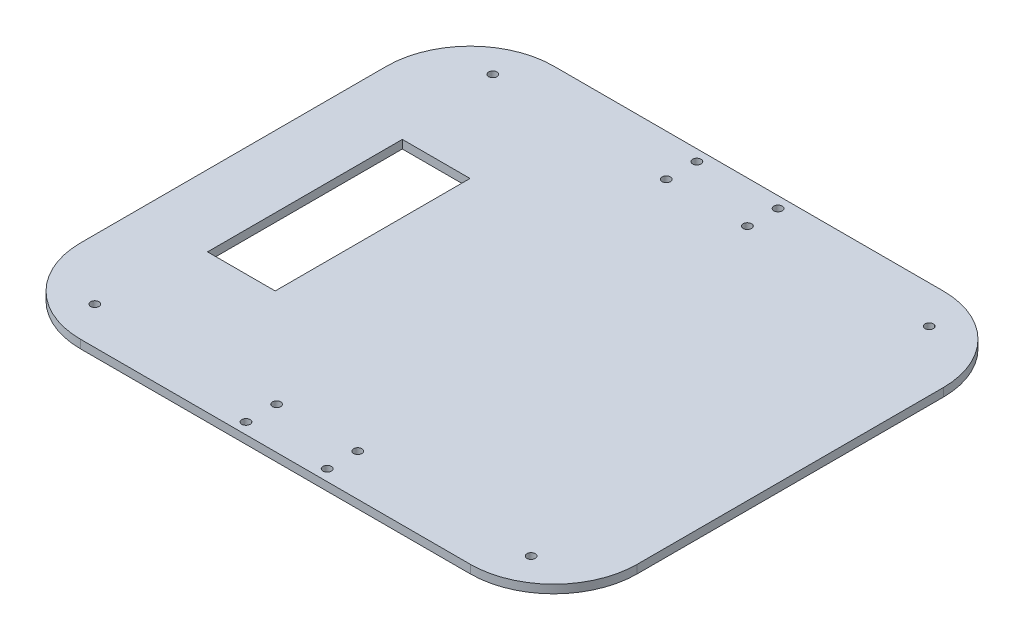
from build123d import *

# Parameters (mm, degrees)
SKETCH1_W           = 200
SKETCH1_H           = 170
BOSS_EXTRUDE1_DEPTH = 3
SKETCH2_W           = 24.321835298
SKETCH2_H           = 70
CUT_EXTRUDE1_DEPTH  = 100
SKETCH3_R           = 1.5
CUT_EXTRUDE2_DEPTH  = 100
SKETCH4_R           = 1.5
CUT_EXTRUDE3_DEPTH  = 100
FILLET1_R           = 30


with BuildPart() as part:
    # Sketch1 → Boss-Extrude1 (new body)
    with BuildSketch(Plane(origin=(0, 0, 0), x_dir=(1, 0, 0), z_dir=(0, 1, 0))):
        Rectangle(SKETCH1_W, SKETCH1_H)
    extrude(amount=BOSS_EXTRUDE1_DEPTH)

    # Sketch2 → Cut-Extrude1 (cut)
    with BuildSketch(Plane(origin=(0, 3, 0), x_dir=(1, 0, 0), z_dir=(0, 1, 0))):
        with Locations((-62.239691906, 0)):
            Rectangle(SKETCH2_W, SKETCH2_H)
    extrude(amount=-CUT_EXTRUDE1_DEPTH, mode=Mode.SUBTRACT)

    # Sketch3 → Cut-Extrude2 (cut)
    with BuildSketch(Plane(origin=(0, 3, 0), x_dir=(1, 0, 0), z_dir=(0, 1, 0))):
        with Locations((-78.38, -71.5)):
            Circle(SKETCH3_R)
        with Locations((-78.38, 71.5)):
            Circle(SKETCH3_R)
        with Locations((78.38, 71.5)):
            Circle(SKETCH3_R)
        with Locations((78.38, -71.5)):
            Circle(SKETCH3_R)
    extrude(amount=-CUT_EXTRUDE2_DEPTH, mode=Mode.SUBTRACT)

    # Sketch4 → Cut-Extrude3 (cut)
    with BuildSketch(Plane(origin=(0, 3, 0), x_dir=(1, 0, 0), z_dir=(0, 1, 0))):
        with Locations((-14.58, -81)):
            Circle(SKETCH4_R)
        with Locations((14.58, -81)):
            Circle(SKETCH4_R)
        with Locations((-14.58, -70)):
            Circle(SKETCH4_R)
        with Locations((14.58, -70)):
            Circle(SKETCH4_R)
        with Locations((-14.58, 81)):
            Circle(SKETCH4_R)
        with Locations((-14.58, 70)):
            Circle(SKETCH4_R)
        with Locations((14.58, 81)):
            Circle(SKETCH4_R)
        with Locations((14.58, 70)):
            Circle(SKETCH4_R)
    extrude(amount=-CUT_EXTRUDE3_DEPTH, mode=Mode.SUBTRACT)

    # Fillet1
    fillet1_edges = [part.edges().sort_by_distance(p)[0] for p in [
        (100, 1.5, 85),
        (-100, 1.5, 85),
        (-100, 1.5, -85),
        (100, 1.5, -85),
    ]]
    fillet(fillet1_edges, radius=FILLET1_R)


solid = part.part
